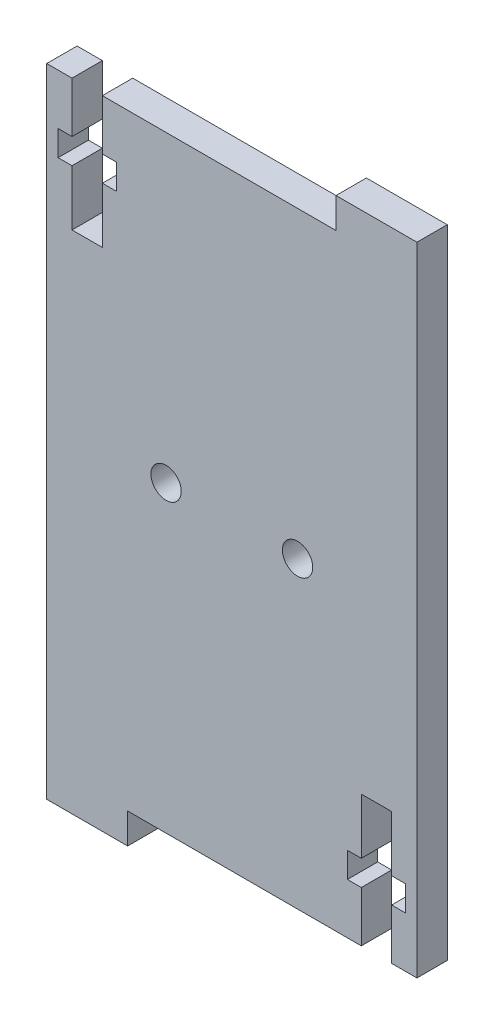
from build123d import *

# Parameters (mm, degrees)
ESBO_O1_R                = 1.5
RESSALTO_EXTRUS_O1_DEPTH = 3


with BuildPart() as part:
    # Esboço1 → Ressalto-extrusão1 (new body)
    with BuildSketch(Plane.XY):
        Polygon((22.3, -30), (22.3, -25), (23.675, -25), (23.675, -22.5), (22.3, -22.5), (22.3, -17), (19.3, -17), (19.3, -22.5), (17.925, -22.5), (17.925, -25), (19.3, -25), (19.3, -30), (-3.8, -30), (-3.8, -33), (-11.8, -33), (-11.8, -30), (-11.8, 8.3), (-11.8, 30), (-9.3, 30), (-9.3, 25), (-10.675, 25), (-10.675, 22.5), (-9.3, 22.5), (-9.3, 17), (-6.3, 17), (-6.3, 22.5), (-4.925, 22.5), (-4.925, 25), (-6.3, 25), (-6.3, 30), (16.8, 30), (16.8, 33), (24.8, 33), (24.8, -30), align=None)
        Circle(ESBO_O1_R, mode=Mode.SUBTRACT)
        with Locations((13, 0)):
            Circle(ESBO_O1_R, mode=Mode.SUBTRACT)
    extrude(amount=RESSALTO_EXTRUS_O1_DEPTH)


solid = part.part
